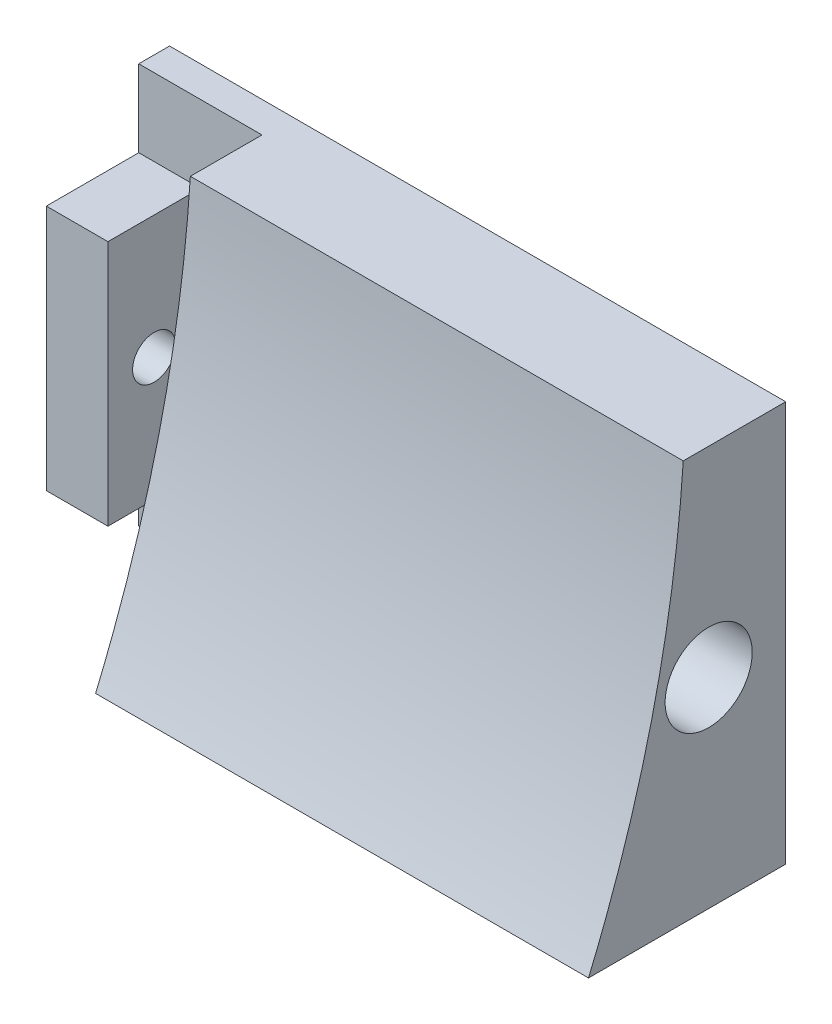
from build123d import *

# Parameters (mm, degrees)
ESQUISSE1_W             = 40
ESQUISSE1_H             = 26
BOSS_EXTRU_1_DEPTH      = 2
ESQUISSE2_W             = 8
ESQUISSE2_H             = 16
BOSS_EXTRU_2_DEPTH      = 4
ESQUISSE3_R             = 1.4
ENL_V_MAT_EXTRU_1_DEPTH = 4
BOSS_EXTRU_3_DEPTH      = 32
ESQUISSE5_R             = 1.4
ENL_V_MAT_EXTRU_2_DEPTH = 41
ESQUISSE6_R             = 2.826620589
ENL_V_MAT_EXTRU_3_DEPTH = 32


with BuildPart() as part:
    # Esquisse1 → Boss.-Extru.1 (new body)
    with BuildSketch(Plane.XY):
        with Locations((8, -24.85)):
            Rectangle(ESQUISSE1_W, ESQUISSE1_H)
    extrude(amount=BOSS_EXTRU_1_DEPTH)

    # Esquisse2 → Boss.-Extru.2 (add)
    with BuildSketch(Plane.ZY.offset(12)):
        with Locations((4, -24.85)):
            Rectangle(ESQUISSE2_W, ESQUISSE2_H)
    extrude(amount=-BOSS_EXTRU_2_DEPTH)

    # Esquisse3 → Enlèv. mat.-Extru.1 (cut)
    with BuildSketch(Plane.ZY.offset(12)):
        with Locations((5, -24.85)):
            Circle(ESQUISSE3_R)
    extrude(amount=-ENL_V_MAT_EXTRU_1_DEPTH, mode=Mode.SUBTRACT)

    # Esquisse4 → Boss.-Extru.3 (add)
    with BuildSketch(Plane(origin=(28, 0, 0), x_dir=(0, 0, -1), z_dir=(1, 0, 0))):
        with BuildLine():
            Line((-6.65, -11.85), (0, -11.85))
            Line((0, -11.85), (0, -37.85))
            Line((0, -37.85), (-12.8, -37.85))
            add(Edge.make_bspline(
                [(-6.65, -11.85), (-7.550626547, -25.384236651), (-12.8, -37.85)],
                knots=[0, 0, 0, 1, 1, 1], degree=2))
        make_face()
    extrude(amount=-BOSS_EXTRU_3_DEPTH)

    # Esquisse5 → Enlèv. mat.-Extru.2 (cut)
    with BuildSketch(Plane.ZY.offset(12)):
        with Locations((5, -24.85)):
            Circle(ESQUISSE5_R)
    extrude(amount=-ENL_V_MAT_EXTRU_2_DEPTH, mode=Mode.SUBTRACT)

    # Esquisse6 → Enlèv. mat.-Extru.3 (cut)
    with BuildSketch(Plane(origin=(28, 0, 0), x_dir=(0, 0, -1), z_dir=(1, 0, 0))):
        with Locations((-5, -24.85)):
            Circle(ESQUISSE6_R)
    extrude(amount=-ENL_V_MAT_EXTRU_3_DEPTH, mode=Mode.SUBTRACT)


solid = part.part
